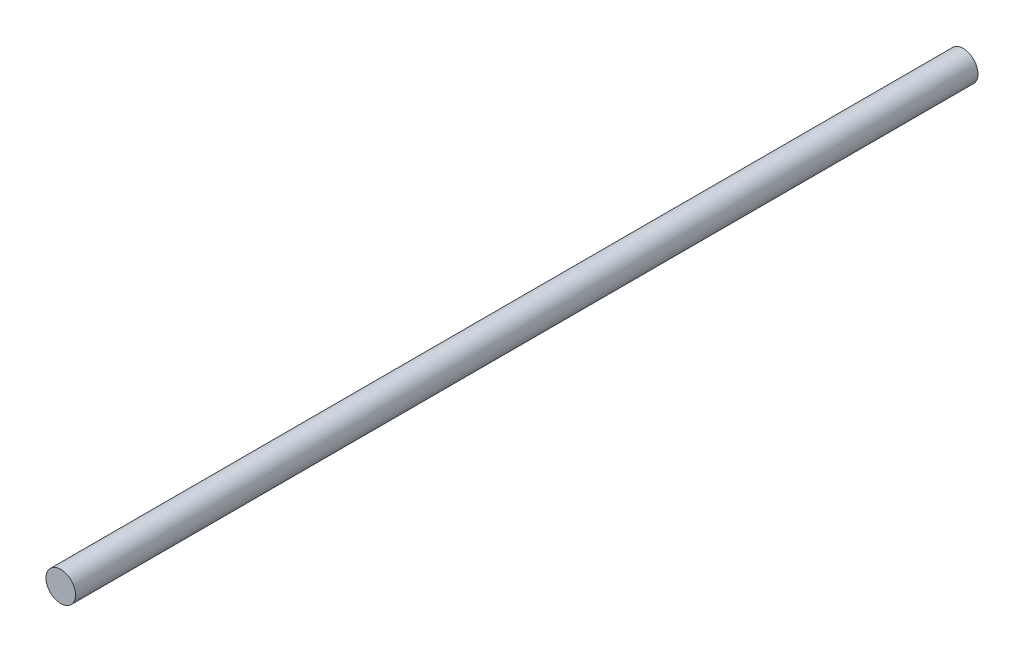
from build123d import *

# Parameters (mm, degrees)
SKETCH1_R           = 12.7
BOSS_EXTRUDE1_DEPTH = 774.7


with BuildPart() as part:
    # Sketch1 → Boss-Extrude1 (new body)
    with BuildSketch(Plane.XY):
        Circle(SKETCH1_R)
    extrude(amount=BOSS_EXTRUDE1_DEPTH)


solid = part.part
